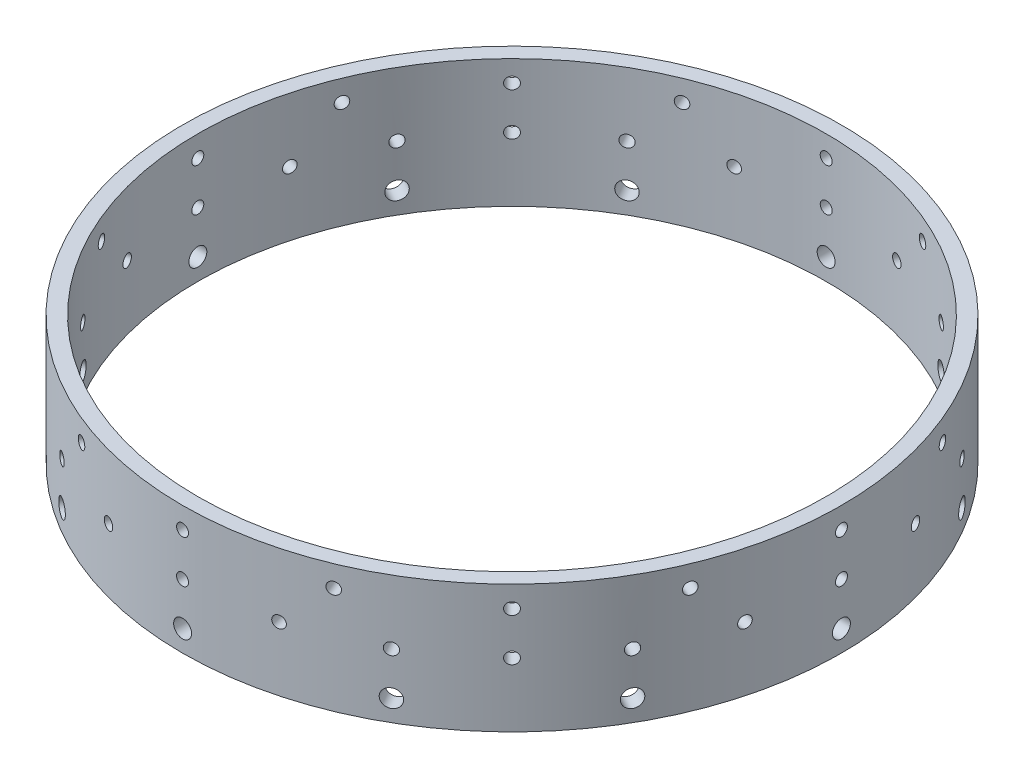
from build123d import *

# Parameters (mm, degrees)
SKETCH1_R           = 68.58
SKETCH1_R_2         = 65.405
BOSS_EXTRUDE1_DEPTH = 26.6319
SKETCH2_R           = 1.8669
CUT_EXTRUDE3_DEPTH  = 90.8939
SKETCH5_R           = 1.2446
CUT_EXTRUDE4_DEPTH  = 90.8939
SKETCH7_R           = 1.2446
CUT_EXTRUDE5_DEPTH  = 90.8939
CIRPATTERN1_COUNT   = 16
CIRPATTERN2_COUNT   = 24
CIRPATTERN3_COUNT   = 12


with BuildPart() as part:
    # Sketch1 → Boss-Extrude1 (new body)
    with BuildSketch(Plane(origin=(0, 0, 0), x_dir=(1, 0, 0), z_dir=(0, 1, 0))):
        Circle(SKETCH1_R)
        Circle(SKETCH1_R_2, mode=Mode.SUBTRACT)
    extrude(amount=BOSS_EXTRUDE1_DEPTH)

    # Sketch2 → Cut-Extrude3 (cut)
    with BuildSketch(Plane(origin=(0, 0, 0), x_dir=(0, 0, -1), z_dir=(1, 0, 0))):
        with Locations((0, 4.445)):
            Circle(SKETCH2_R)
    cut_extrude3 = extrude(amount=-CUT_EXTRUDE3_DEPTH, mode=Mode.SUBTRACT)

    # Sketch5 → Cut-Extrude4 (cut)
    with BuildSketch(Plane(origin=(0, 0, 0), x_dir=(0, 0, -1), z_dir=(1, 0, 0))):
        with Locations((0, 13.335)):
            Circle(SKETCH5_R)
    cut_extrude4 = extrude(amount=-CUT_EXTRUDE4_DEPTH, mode=Mode.SUBTRACT)

    # Sketch7 → Cut-Extrude5 (cut)
    with BuildSketch(Plane(origin=(0, 0, 0), x_dir=(0, 0, -1), z_dir=(1, 0, 0))):
        with Locations((0, 22.225)):
            Circle(SKETCH7_R)
    cut_extrude5 = extrude(amount=-CUT_EXTRUDE5_DEPTH, mode=Mode.SUBTRACT)

    # CirPattern1: Cut-Extrude5 ×16 about axis
    cirpattern1_axis = Axis((0, 0, 0), (0, 1, 0))
    for i in range(1, CIRPATTERN1_COUNT):
        add(cut_extrude5.rotate(cirpattern1_axis, i * 360 / CIRPATTERN1_COUNT), mode=Mode.SUBTRACT)

    # CirPattern2: Cut-Extrude4 ×24 about axis
    cirpattern2_axis = Axis((0, 0, 0), (0, 1, 0))
    for i in range(1, CIRPATTERN2_COUNT):
        add(cut_extrude4.rotate(cirpattern2_axis, i * 360 / CIRPATTERN2_COUNT), mode=Mode.SUBTRACT)

    # CirPattern3: Cut-Extrude3 ×12 about axis
    cirpattern3_axis = Axis((0, 0, 0), (0, 1, 0))
    for i in range(1, CIRPATTERN3_COUNT):
        add(cut_extrude3.rotate(cirpattern3_axis, i * 360 / CIRPATTERN3_COUNT), mode=Mode.SUBTRACT)


solid = part.part
